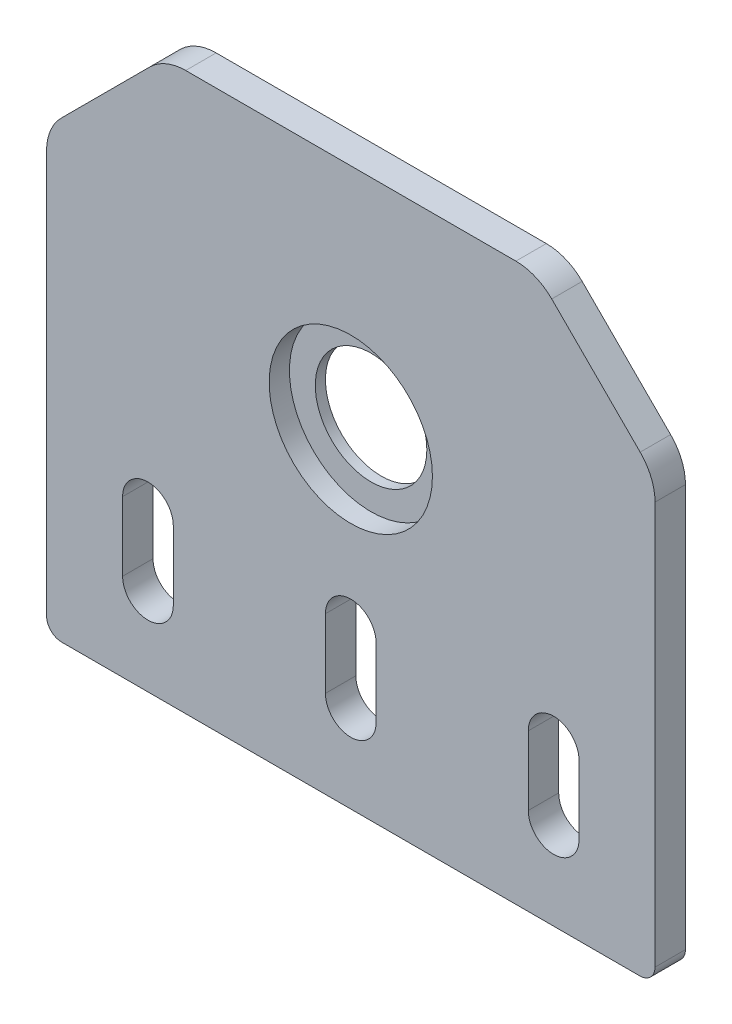
from build123d import *

# Parameters (mm, degrees)
MODEL_R             = 5.5
BOSS_EXTRUDE1_DEPTH = 3
SKETCH2_R           = 8.05
CUT_EXTRUDE1_DEPTH  = 2


with BuildPart() as part:
    # Model → Boss-Extrude1 (new body)
    with BuildSketch(Plane.XY):
        with BuildLine():
            Line((-19.814466094, 53.465533906), (-28.535533906, 44.744466094))
            ThreePointArc((-28.535533906, 44.744466094), (-29.619397663, 43.12234935), (-30, 41.208932188))
            Line((-30, 41.208932188), (-30, 1.5))
            ThreePointArc((-30, 1.5), (-29.560660172, 0.439339828), (-28.5, 0))
            Line((-28.5, 0), (28.5, 0))
            ThreePointArc((28.5, 0), (29.560660172, 0.439339828), (30, 1.5))
            Line((30, 1.5), (30, 41.208932188))
            ThreePointArc((30, 41.208932188), (29.619397663, 43.12234935), (28.535533906, 44.744466094))
            Line((28.535533906, 44.744466094), (19.814466094, 53.465533906))
            ThreePointArc((19.814466094, 53.465533906), (18.19234935, 54.549397663), (16.278932188, 54.93))
            Line((16.278932188, 54.93), (-16.278932188, 54.93))
            ThreePointArc((-16.278932188, 54.93), (-18.19234935, 54.549397663), (-19.814466094, 53.465533906))
        make_face()
        with Locations((0, 32.43)):
            Circle(MODEL_R, mode=Mode.SUBTRACT)
        with BuildLine():
            Line((22.5, 8.63), (22.5, 15.43))
            ThreePointArc((22.5, 15.43), (20, 17.93), (17.5, 15.43))
            Line((17.5, 15.43), (17.5, 8.63))
            ThreePointArc((17.5, 8.63), (20, 6.13), (22.5, 8.63))
        make_face(mode=Mode.SUBTRACT)
        with BuildLine():
            Line((-22.5, 8.63), (-22.5, 15.43))
            ThreePointArc((-22.5, 15.43), (-20, 17.93), (-17.5, 15.43))
            Line((-17.5, 15.43), (-17.5, 8.63))
            ThreePointArc((-17.5, 8.63), (-20, 6.13), (-22.5, 8.63))
        make_face(mode=Mode.SUBTRACT)
        with BuildLine():
            Line((-2.5, 8.63), (-2.5, 15.43))
            ThreePointArc((-2.5, 15.43), (0, 17.93), (2.5, 15.43))
            Line((2.5, 15.43), (2.5, 8.63))
            ThreePointArc((2.5, 8.63), (0, 6.13), (-2.5, 8.63))
        make_face(mode=Mode.SUBTRACT)
    extrude(amount=BOSS_EXTRUDE1_DEPTH)

    # Sketch2 → Cut-Extrude1 (cut)
    with BuildSketch(Plane.XY.offset(3)):
        with Locations((0, 32.43)):
            Circle(SKETCH2_R)
    extrude(amount=-CUT_EXTRUDE1_DEPTH, mode=Mode.SUBTRACT)


solid = part.part
